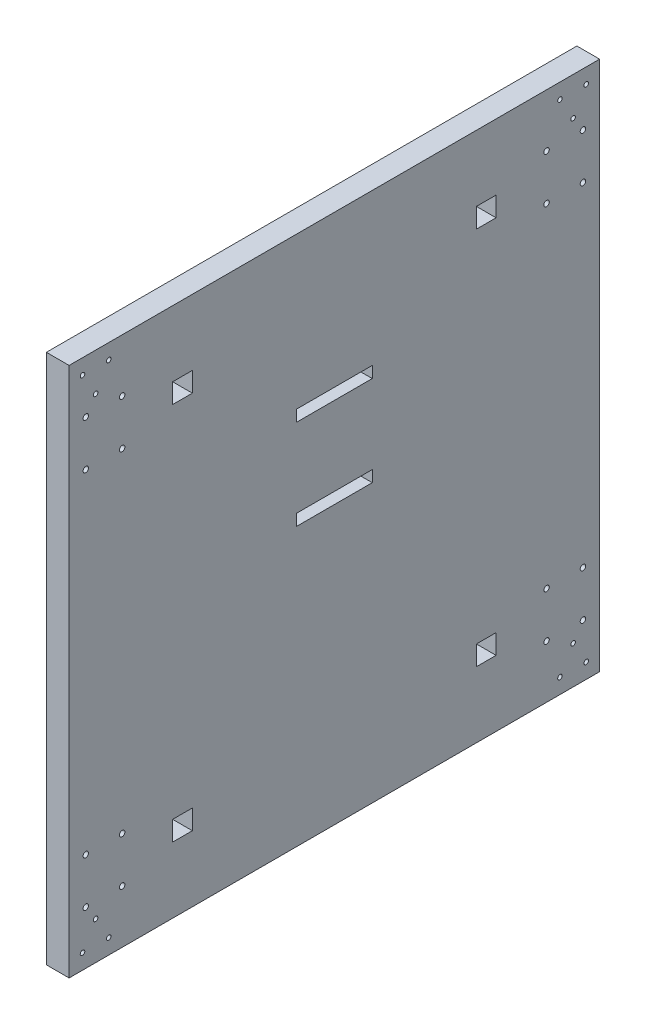
from build123d import *

# Parameters (mm, degrees)
SKETCH2_W           = 350
SKETCH2_H           = 350
SKETCH2_R           = 1.8
SKETCH2_R_2         = 1.5
SKETCH2_W_2         = 12.9979177
SKETCH2_H_2         = 12.99791772
BOSS_EXTRUDE2_DEPTH = 15


with BuildPart() as part:
    # Sketch2 → Boss-Extrude2 (new body)
    with BuildSketch(Plane(origin=(0, 0, 0), x_dir=(0, 0, -1), z_dir=(1, 0, 0))):
        with Locations((-161.173220858, -113.174460432)):
            Rectangle(SKETCH2_W, SKETCH2_H)
        with Locations((-301.173220858, 26.825539568)):
            Circle(SKETCH2_R, mode=Mode.SUBTRACT)
        with Locations((-301.173220858, -3.174460432)):
            Circle(SKETCH2_R, mode=Mode.SUBTRACT)
        with Locations((-325.173220858, -3.174460432)):
            Circle(SKETCH2_R, mode=Mode.SUBTRACT)
        with Locations((-325.173220858, 26.825539568)):
            Circle(SKETCH2_R, mode=Mode.SUBTRACT)
        with Locations((-301.173220858, -223.174460432)):
            Circle(SKETCH2_R, mode=Mode.SUBTRACT)
        with Locations((-325.173220858, -223.174460432)):
            Circle(SKETCH2_R, mode=Mode.SUBTRACT)
        with Locations((-301.173220858, -253.174460432)):
            Circle(SKETCH2_R, mode=Mode.SUBTRACT)
        with Locations((-325.173220858, -253.174460432)):
            Circle(SKETCH2_R, mode=Mode.SUBTRACT)
        with Locations((-21.173220858, -3.174460432)):
            Circle(SKETCH2_R, mode=Mode.SUBTRACT)
        with Locations((2.826779142, -3.174460432)):
            Circle(SKETCH2_R, mode=Mode.SUBTRACT)
        with Locations((2.826779142, 26.825539568)):
            Circle(SKETCH2_R, mode=Mode.SUBTRACT)
        with Locations((-21.173220858, 26.825539568)):
            Circle(SKETCH2_R, mode=Mode.SUBTRACT)
        with Locations((2.826779142, -223.174460432)):
            Circle(SKETCH2_R, mode=Mode.SUBTRACT)
        with Locations((-21.173220858, -223.174460432)):
            Circle(SKETCH2_R, mode=Mode.SUBTRACT)
        with Locations((-21.173220858, -253.174460432)):
            Circle(SKETCH2_R, mode=Mode.SUBTRACT)
        with Locations((2.826779142, -253.174460432)):
            Circle(SKETCH2_R, mode=Mode.SUBTRACT)
        with Locations((-3.673220858, -263.174460432)):
            Circle(SKETCH2_R_2, mode=Mode.SUBTRACT)
        with Locations((4.98703318, -278.174460432)):
            Circle(SKETCH2_R_2, mode=Mode.SUBTRACT)
        with Locations((-12.333474896, -278.174460432)):
            Circle(SKETCH2_R_2, mode=Mode.SUBTRACT)
        with Locations((-12.333474896, 51.825539568)):
            Circle(SKETCH2_R_2, mode=Mode.SUBTRACT)
        with Locations((4.98703318, 51.825539568)):
            Circle(SKETCH2_R_2, mode=Mode.SUBTRACT)
        with Locations((-3.673220858, 36.825539568)):
            Circle(SKETCH2_R_2, mode=Mode.SUBTRACT)
        with Locations((-318.673220858, 36.825539568)):
            Circle(SKETCH2_R_2, mode=Mode.SUBTRACT)
        with Locations((-327.333474896, 51.825539568)):
            Circle(SKETCH2_R_2, mode=Mode.SUBTRACT)
        with Locations((-310.01296682, 51.825539568)):
            Circle(SKETCH2_R_2, mode=Mode.SUBTRACT)
        with Locations((-327.333474896, -278.174460432)):
            Circle(SKETCH2_R_2, mode=Mode.SUBTRACT)
        with Locations((-310.01296682, -278.174460432)):
            Circle(SKETCH2_R_2, mode=Mode.SUBTRACT)
        with Locations((-318.673220858, -263.174460432)):
            Circle(SKETCH2_R_2, mode=Mode.SUBTRACT)
        Polygon((-161.173220858, -38.174460432), (-136.173220858, -38.174460432), (-136.173220858, -45.674460432), (-186.173220858, -45.674460432), (-186.173220858, -38.174460432), align=None, mode=Mode.SUBTRACT)
        with Locations((-60.973061718, 11.825539568)):
            Rectangle(SKETCH2_W_2, SKETCH2_H_2, mode=Mode.SUBTRACT)
        with Locations((-261.373379998, 11.825539568)):
            Rectangle(SKETCH2_W_2, SKETCH2_H_2, mode=Mode.SUBTRACT)
        with Locations((-60.973061718, -238.174460432)):
            Rectangle(SKETCH2_W_2, SKETCH2_H_2, mode=Mode.SUBTRACT)
        with Locations((-261.373379998, -238.174460432)):
            Rectangle(SKETCH2_W_2, SKETCH2_H_2, mode=Mode.SUBTRACT)
        Polygon((-161.173220858, -105.174460432), (-136.173220858, -105.174460432), (-136.173220858, -97.674460432), (-186.173220858, -97.674460432), (-186.173220858, -105.174460432), align=None, mode=Mode.SUBTRACT)
    extrude(amount=BOSS_EXTRUDE2_DEPTH)


solid = part.part
